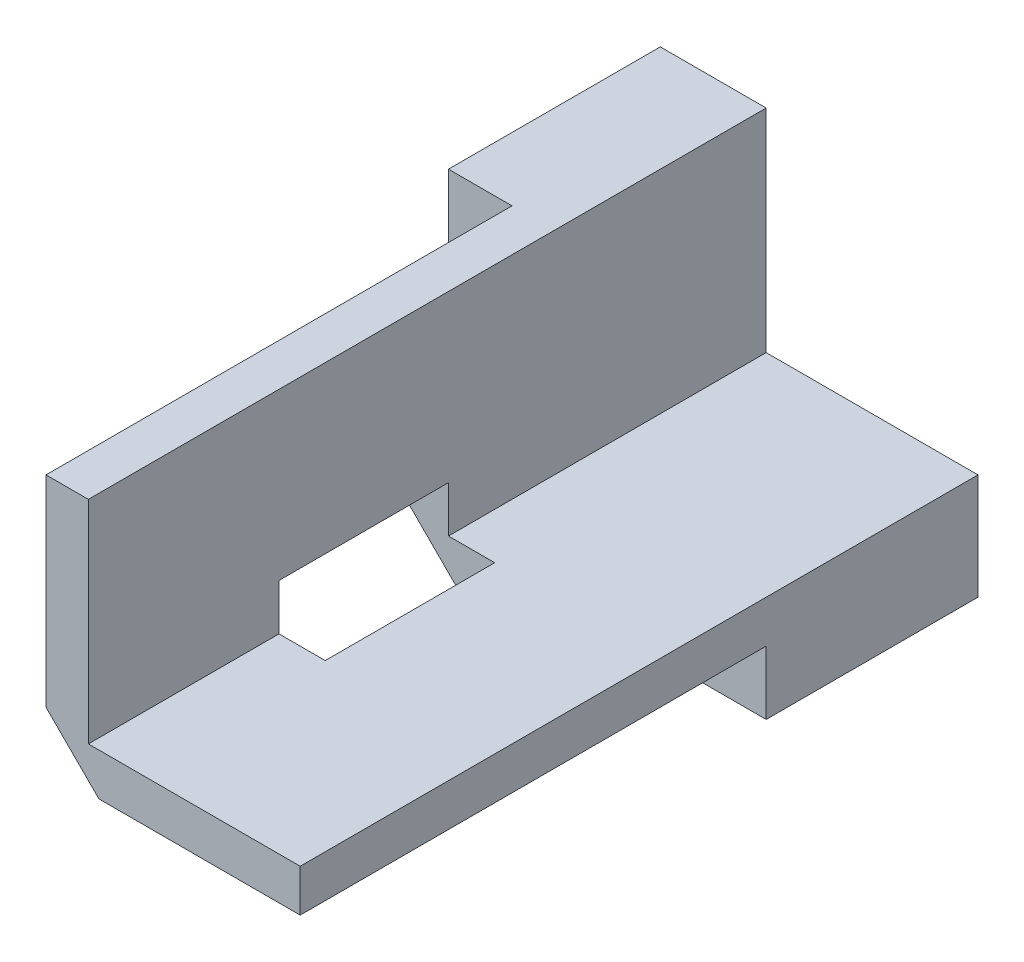
from build123d import *

# Parameters (mm, degrees)
EXTRUDE_1_DEPTH     = 32
CHAMFER_1_SIZE      = 2
CUT_EXTRUDE_1_DEPTH = 22
SKETCH_3_W          = 8
SKETCH_3_H          = 28
CUT_EXTRUDE_2_DEPTH = 7.2
CHAMFER_2_SIZE      = 2.5


with BuildPart() as part:
    # Эскиз1 → Бобышка-Вытянуть1 (new body)
    with BuildSketch(Plane.XY):
        Polygon((0, 10), (0, 0), (10, 0), (10, -5), (-5, -5), (-5, 10), align=None)
    extrude(amount=EXTRUDE_1_DEPTH)

    # Фаска1
    chamfer_1_edges = [part.edges().sort_by_distance(p)[0] for p in [
        (-5, -5, 16),
    ]]
    chamfer(chamfer_1_edges, length=CHAMFER_1_SIZE)

    # Эскиз2 → Вырез-Вытянуть1 (cut)
    with BuildSketch(Plane.XY.offset(32)):
        Polygon((-2, -2), (-2, 10), (-5, 10), (-5, -3), (-3, -5), (10, -5), (10, -2), align=None)
    extrude(amount=-CUT_EXTRUDE_1_DEPTH, mode=Mode.SUBTRACT)

    # Эскиз3 → Вырез-Вытянуть2 (cut)
    with BuildSketch(Plane(origin=(-4, -4, 0), x_dir=(0, 0, 1), z_dir=(-0.707106781, -0.707106781, 0))):
        with Locations((19, 0)):
            Rectangle(SKETCH_3_W, SKETCH_3_H)
    extrude(amount=-CUT_EXTRUDE_2_DEPTH, mode=Mode.SUBTRACT)

    # Фаска2
    chamfer_2_edges = [part.edges().sort_by_distance(p)[0] for p in [
        (-2, -2, 12.5),
        (-2, -2, 27.5),
    ]]
    chamfer(chamfer_2_edges, length=CHAMFER_2_SIZE)

    # Эскиз4 → Отверстие обработанное метчиком #4-401 (revolve, cut)
    with BuildSketch(Plane(origin=(-2, -2, 0), x_dir=(0, 1, 0), z_dir=(1, 0, 0))):
        Polygon((0, 0), (0, 10), (1.651, 10), (1.4224, 9.839932557), (1.4224, 0.160067443), (1.651, 0), align=None)
    revolve(axis=Axis((-2, -2, -6.35), (0, 0, 1)), mode=Mode.SUBTRACT)


solid = part.part
